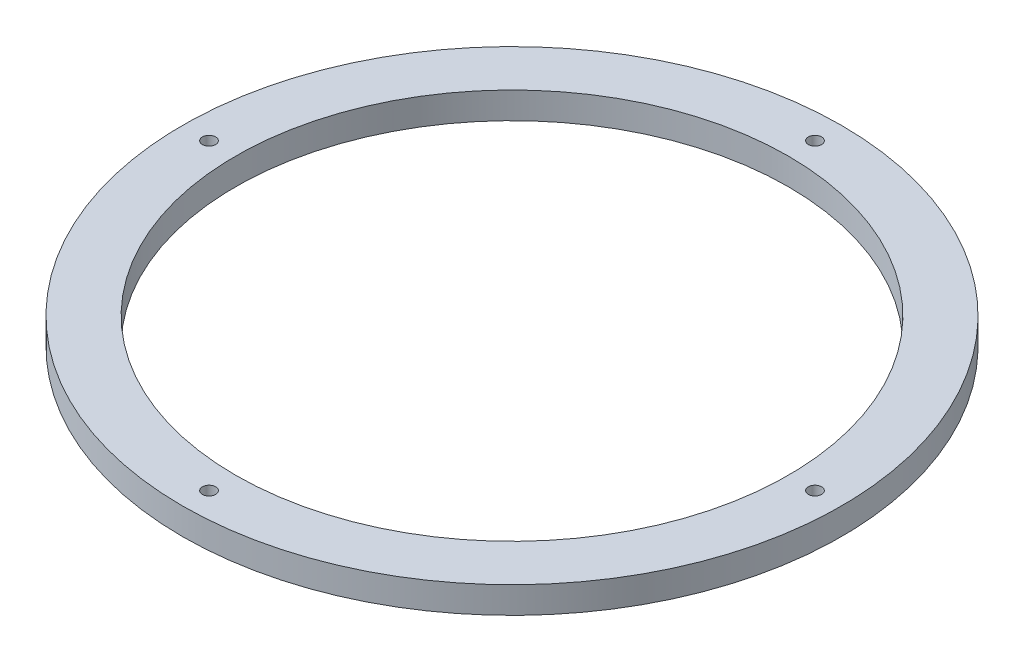
from build123d import *

# Parameters (mm, degrees)
SKETCH1_R           = 39.37
SKETCH1_R_2         = 33.02
SKETCH1_R_3         = 0.79375
BOSS_EXTRUDE1_DEPTH = 3.175


with BuildPart() as part:
    # Sketch1 → Boss-Extrude1 (new body)
    with BuildSketch(Plane(origin=(0, 0, 0), x_dir=(1, 0, 0), z_dir=(0, 1, 0))):
        Circle(SKETCH1_R)
        Circle(SKETCH1_R_2, mode=Mode.SUBTRACT)
        with Locations((36.195, 0)):
            Circle(SKETCH1_R_3, mode=Mode.SUBTRACT)
        with Locations((0, -36.195)):
            Circle(SKETCH1_R_3, mode=Mode.SUBTRACT)
        with Locations((-36.195, 0)):
            Circle(SKETCH1_R_3, mode=Mode.SUBTRACT)
        with Locations((0, 36.195)):
            Circle(SKETCH1_R_3, mode=Mode.SUBTRACT)
    extrude(amount=BOSS_EXTRUDE1_DEPTH)


solid = part.part
